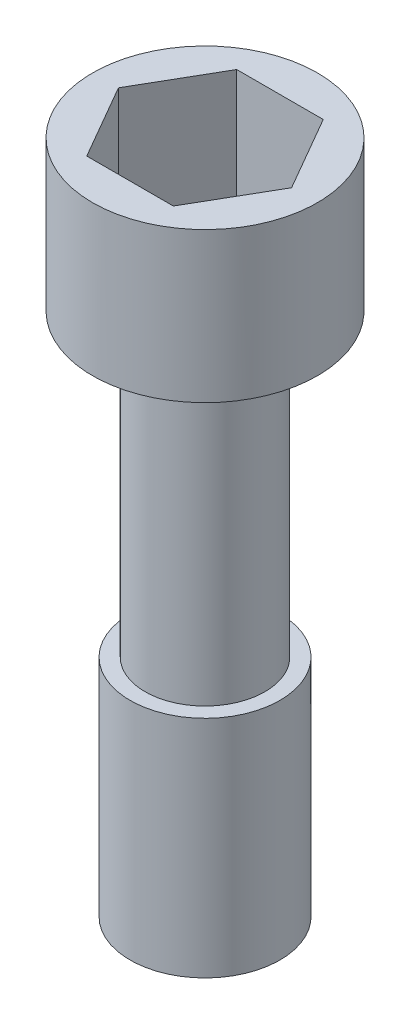
from build123d import *

# Parameters (mm, degrees)
SKETCH1_R           = 7.5
BOSS_EXTRUDE1_DEPTH = 8
SKETCH2_R           = 7.5
BOSS_EXTRUDE2_DEPTH = 2
SKETCH3_R           = 4
BOSS_EXTRUDE3_DEPTH = 20
SKETCH4_R           = 5
BOSS_EXTRUDE4_DEPTH = 15


with BuildPart() as part:
    # Sketch1 → Boss-Extrude1 (new body)
    with BuildSketch(Plane(origin=(0, 0, 0), x_dir=(1, 0, 0), z_dir=(0, 1, 0))):
        Circle(SKETCH1_R)
        Polygon((5.773502692, 0), (2.886751346, 5), (-2.886751346, 5), (-5.773502692, 0), (-2.886751346, -5), (2.886751346, -5), align=None, mode=Mode.SUBTRACT)
    extrude(amount=BOSS_EXTRUDE1_DEPTH)

    # Sketch2 → Boss-Extrude2 (add)
    with BuildSketch(Plane.XZ):
        Circle(SKETCH2_R)
    extrude(amount=BOSS_EXTRUDE2_DEPTH)

    # Sketch3 → Boss-Extrude3 (add)
    with BuildSketch(Plane.XZ.offset(2)):
        Circle(SKETCH3_R)
    extrude(amount=BOSS_EXTRUDE3_DEPTH)

    # Sketch4 → Boss-Extrude4 (add)
    with BuildSketch(Plane.XZ.offset(22)):
        Circle(SKETCH4_R)
    extrude(amount=BOSS_EXTRUDE4_DEPTH)


solid = part.part
